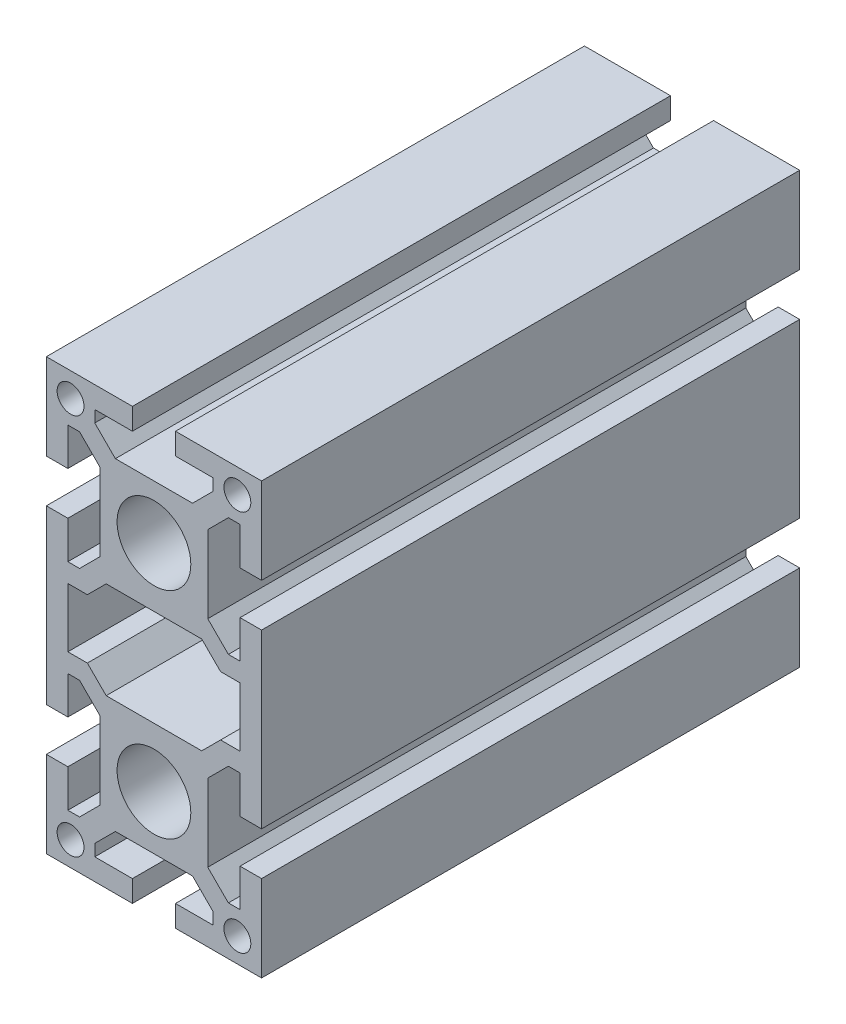
from build123d import *

# Parameters (mm, degrees)
SKETCH1_R      = 2.5
SKETCH1_R_2    = 6.85
EXTRUDE1_DEPTH = 100


with BuildPart() as part:
    # Sketch1 → Extrude1 (new body)
    with BuildSketch(Plane.XY):
        Polygon((-20, -24), (-16, -24), (-16, -31), (-13.828427, -31), (-10, -27.171573), (-10, -12.828427), (-13.828427, -9), (-16, -9), (-16, -16), (-20, -16), (-20, 16), (-16, 16), (-16, 9), (-13.828427, 9), (-10, 12.828427), (-10, 27.171573), (-13.828427, 31), (-16, 31), (-16, 24), (-20, 24), (-20, 40), (-4, 40), (-4, 36), (-11, 36), (-11, 33.828427), (-7.171573, 30), (7.171573, 30), (11, 33.828427), (11, 36), (4, 36), (4, 40), (20, 40), (20, 24), (16, 24), (16, 31), (13.828427, 31), (10, 27.171573), (10, 12.828427), (13.828427, 9), (16, 9), (16, 16), (20, 16), (20, -16), (16, -16), (16, -9), (13.828427, -9), (10, -12.828427), (10, -27.171573), (13.828427, -31), (16, -31), (16, -24), (20, -24), (20, -40), (4, -40), (4, -36), (11, -36), (11, -33.828427), (7.171573, -30), (-7.171573, -30), (-11, -33.828427), (-11, -36), (-4, -36), (-4, -40), (-20, -40), align=None)
        with Locations((-15.5, -35.5)):
            Circle(SKETCH1_R, mode=Mode.SUBTRACT)
        with Locations((-15.5, 35.5)):
            Circle(SKETCH1_R, mode=Mode.SUBTRACT)
        with Locations((15.5, -35.5)):
            Circle(SKETCH1_R, mode=Mode.SUBTRACT)
        with Locations((15.5, 35.5)):
            Circle(SKETCH1_R, mode=Mode.SUBTRACT)
        with Locations((0, -20)):
            Circle(SKETCH1_R_2, mode=Mode.SUBTRACT)
        with Locations((0, 20)):
            Circle(SKETCH1_R_2, mode=Mode.SUBTRACT)
        Polygon((-8.87868, -9), (8.87868, -9), (12.37868, -5.5), (16, -5.5), (16, 5.5), (12.37868, 5.5), (8.87868, 9), (-8.87868, 9), (-12.37868, 5.5), (-16, 5.5), (-16, -5.5), (-12.37868, -5.5), align=None, mode=Mode.SUBTRACT)
    extrude(amount=-EXTRUDE1_DEPTH)


solid = part.part
